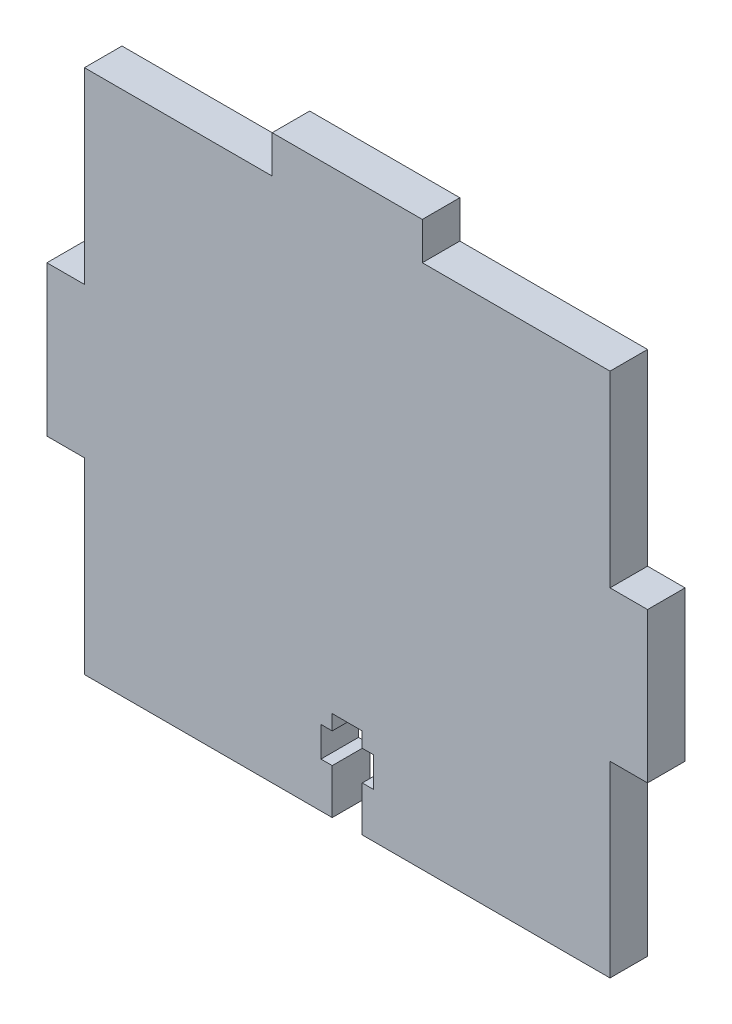
from build123d import *

# Parameters (mm, degrees)
BOSS_EXTRUDE1_DEPTH = 5
CUT_EXTRUDE1_DEPTH  = 10


with BuildPart() as part:
    # Sketch1 → Boss-Extrude1 (new body)
    with BuildSketch(Plane.XY):
        Polygon((-35, 35), (-10, 35), (-10, 40), (10, 40), (10, 35), (35, 35), (35, 10), (40, 10), (40, -10), (35, -10), (35, -35), (-35, -35), (-35, -10), (-40, -10), (-40, 10), (-35, 10), align=None)
    extrude(amount=BOSS_EXTRUDE1_DEPTH)

    # Sketch2 → Cut-Extrude1 (cut)
    with BuildSketch(Plane.XY.offset(5)):
        Polygon((-2, -35), (-2, -29), (-3.5, -29), (-3.5, -25), (-2, -25), (-2, -23), (2, -23), (2, -25), (3.5, -25), (3.5, -29), (2, -29), (2, -35), align=None)
    extrude(amount=-CUT_EXTRUDE1_DEPTH, mode=Mode.SUBTRACT)


solid = part.part
